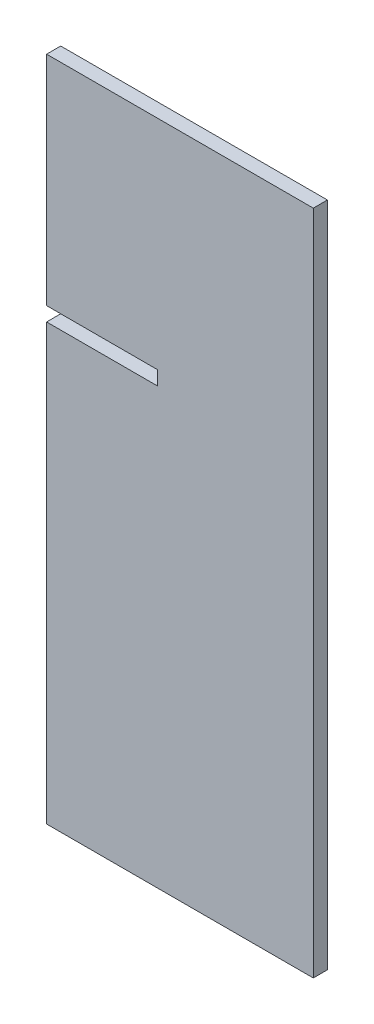
from build123d import *

# Parameters (mm, degrees)
SKETCH1_W           = 60
SKETCH1_H           = 150
BOSS_EXTRUDE1_DEPTH = 3.175
SKETCH2_W           = 25
SKETCH2_H           = 3.175
CUT_EXTRUDE1_DEPTH  = 3.175


with BuildPart() as part:
    # Sketch1 → Boss-Extrude1 (new body)
    with BuildSketch(Plane.XY):
        Rectangle(SKETCH1_W, SKETCH1_H)
    extrude(amount=BOSS_EXTRUDE1_DEPTH)

    # Sketch2 → Cut-Extrude1 (cut)
    with BuildSketch(Plane.XY.offset(3.175)):
        with Locations((-17.5, 24.4125)):
            Rectangle(SKETCH2_W, SKETCH2_H)
    extrude(amount=-CUT_EXTRUDE1_DEPTH, mode=Mode.SUBTRACT)


solid = part.part
